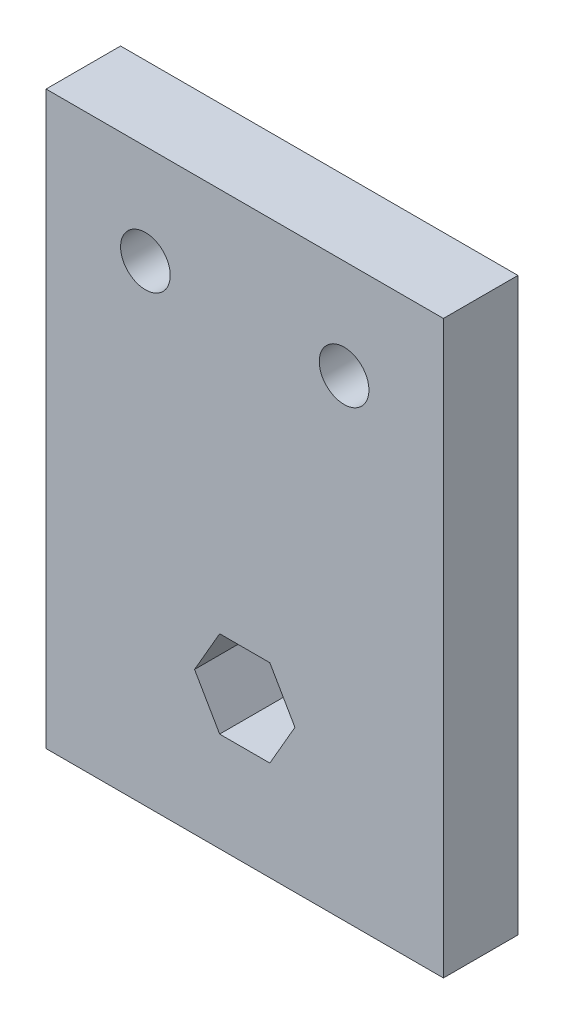
from build123d import *

# Parameters (mm, degrees)
SKETCH2_W      = 50.8
SKETCH2_H      = 73.025
SKETCH2_R      = 3.175
EXTRUDE1_DEPTH = 9.525


with BuildPart() as part:
    # Sketch2 → Extrude1 (new body)
    with BuildSketch(Plane.XY):
        with Locations((25.4, 36.5125)):
            Rectangle(SKETCH2_W, SKETCH2_H)
        with Locations((12.7, 60.325)):
            Circle(SKETCH2_R, mode=Mode.SUBTRACT)
        with Locations((38.1, 60.325)):
            Circle(SKETCH2_R, mode=Mode.SUBTRACT)
        Polygon((31.815804866, 18.25625), (28.607902433, 23.8125), (22.192097567, 23.8125), (18.984195134, 18.25625), (22.192097567, 12.7), (28.607902433, 12.7), align=None, mode=Mode.SUBTRACT)
    extrude(amount=EXTRUDE1_DEPTH)


solid = part.part
